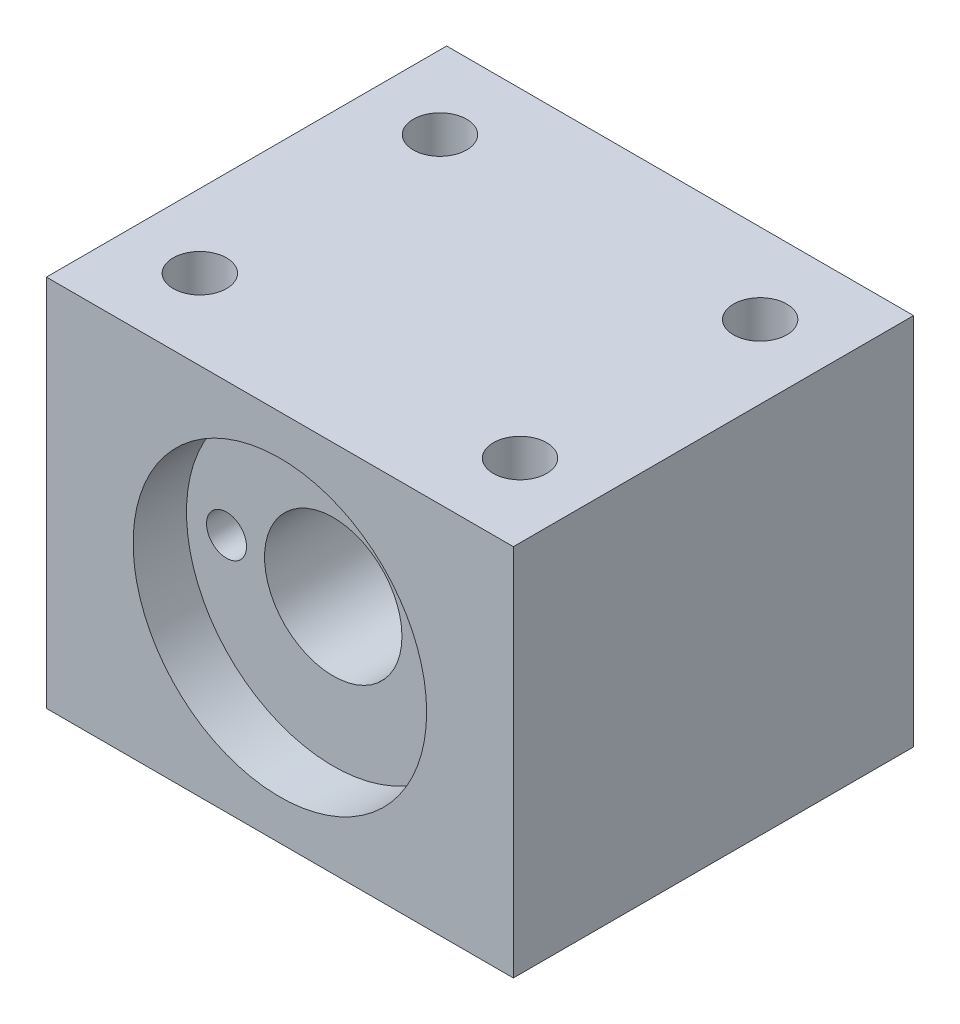
from build123d import *

# Parameters (mm, degrees)
ESBO_O1_W                = 35
ESBO_O1_H                = 28
RESSALTO_EXTRUS_O1_DEPTH = 30
ESBO_O2_R                = 5.15
CORTE_EXTRUS_O1_DEPTH    = 31
ESBO_O3_R                = 11
CORTE_EXTRUS_O2_DEPTH    = 4
ESBO_O4_R                = 1.5
CORTE_EXTRUS_O3_DEPTH    = 10
ESBO_O6_R                = 2
CORTE_EXTRUS_O4_DEPTH    = 7


with BuildPart() as part:
    # Esboço1 → Ressalto-extrusão1 (new body)
    with BuildSketch(Plane.XY):
        Rectangle(ESBO_O1_W, ESBO_O1_H)
    extrude(amount=RESSALTO_EXTRUS_O1_DEPTH)

    # Esboço2 → Corte-extrusão1 (cut, through all)
    with BuildSketch(Plane.XY.offset(30)):
        Circle(ESBO_O2_R)
    extrude(amount=-CORTE_EXTRUS_O1_DEPTH, mode=Mode.SUBTRACT)

    # Esboço3 → Corte-extrusão2 (cut)
    with BuildSketch(Plane.XY.offset(30)):
        Circle(ESBO_O3_R)
    extrude(amount=-CORTE_EXTRUS_O2_DEPTH, mode=Mode.SUBTRACT)

    # Esboço4 → Corte-extrusão3 (cut)
    with BuildSketch(Plane.XY.offset(26)):
        with Locations((-8, 0)):
            Circle(ESBO_O4_R)
        with Locations((8, 0)):
            Circle(ESBO_O4_R)
    extrude(amount=-CORTE_EXTRUS_O3_DEPTH, mode=Mode.SUBTRACT)

    # Esboço6 → Corte-extrusão4 (cut)
    with BuildSketch(Plane(origin=(0, 14, 0), x_dir=(1, 0, 0), z_dir=(0, 1, 0))):
        with Locations((-12, -24)):
            Circle(ESBO_O6_R)
        with Locations((12, -24)):
            Circle(ESBO_O6_R)
        with Locations((12, -6)):
            Circle(ESBO_O6_R)
        with Locations((-12, -6)):
            Circle(ESBO_O6_R)
    extrude(amount=-CORTE_EXTRUS_O4_DEPTH, mode=Mode.SUBTRACT)


solid = part.part
